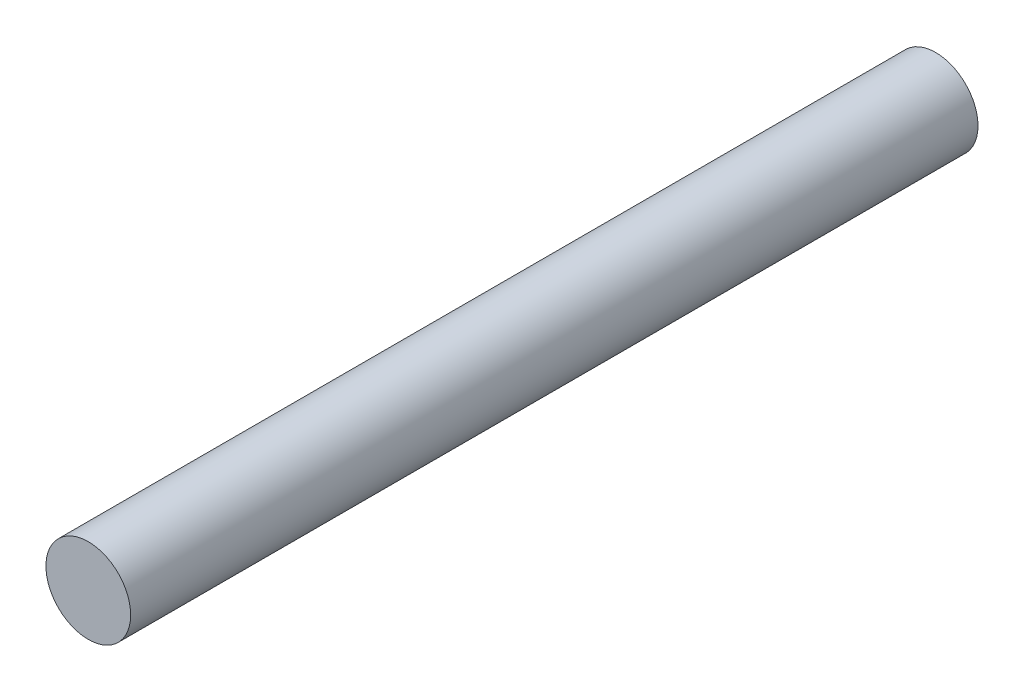
from build123d import *

# Parameters (mm, degrees)
SKETCH_1_R      = 2.5
EXTRUDE_1_DEPTH = 50


with BuildPart() as part:
    # 草图1 → 凸台-拉伸1 (new body)
    with BuildSketch(Plane.XY):
        Circle(SKETCH_1_R)
    extrude(amount=EXTRUDE_1_DEPTH)


solid = part.part
